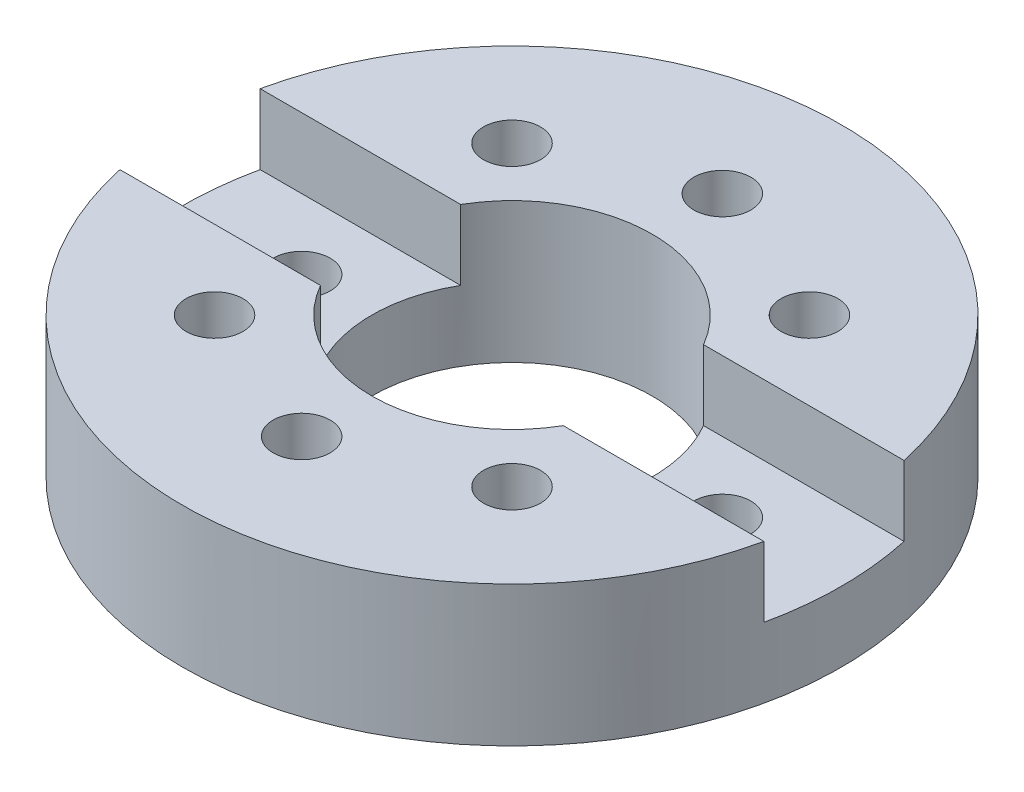
from build123d import *

# Parameters (mm, degrees)
SKETCH1_R           = 2.35
SKETCH1_R_2         = 0.2032
BOSS_EXTRUDE1_DEPTH = 1
SKETCH3_R           = 1
CUT_EXTRUDE1_DEPTH  = 2
CUT_EXTRUDE2_DEPTH  = 0.5


with BuildPart() as part:
    # Sketch1 → Boss-Extrude1 (new body)
    with BuildSketch(Plane(origin=(0, 0, 0), x_dir=(1, 0, 0), z_dir=(0, 1, 0))):
        Circle(SKETCH1_R)
        with Locations((0, 1.5)):
            Circle(SKETCH1_R_2, mode=Mode.SUBTRACT)
        with Locations((1.060660172, 1.060660172)):
            Circle(SKETCH1_R_2, mode=Mode.SUBTRACT)
        with Locations((1.5, 0)):
            Circle(SKETCH1_R_2, mode=Mode.SUBTRACT)
        with Locations((1.060660172, -1.060660172)):
            Circle(SKETCH1_R_2, mode=Mode.SUBTRACT)
        with Locations((0, -1.5)):
            Circle(SKETCH1_R_2, mode=Mode.SUBTRACT)
        with Locations((-1.060660172, -1.060660172)):
            Circle(SKETCH1_R_2, mode=Mode.SUBTRACT)
        with Locations((-1.5, 0)):
            Circle(SKETCH1_R_2, mode=Mode.SUBTRACT)
        with Locations((-1.060660172, 1.060660172)):
            Circle(SKETCH1_R_2, mode=Mode.SUBTRACT)
    extrude(amount=BOSS_EXTRUDE1_DEPTH)

    # Sketch3 → Cut-Extrude1 (cut, through all)
    with BuildSketch(Plane(origin=(0, 1, 0), x_dir=(1, 0, 0), z_dir=(0, 1, 0))):
        Circle(SKETCH3_R)
    extrude(amount=-CUT_EXTRUDE1_DEPTH, mode=Mode.SUBTRACT)

    # Sketch4 → Cut-Extrude2 (cut)
    with BuildSketch(Plane(origin=(0, 1, 0), x_dir=(1, 0, 0), z_dir=(0, 1, 0))):
        with BuildLine():
            Line((-2.35, 0.5), (2.35, 0.5))
            ThreePointArc((2.35, 0.5), (2.85, 0), (2.35, -0.5))
            Line((2.35, -0.5), (-2.35, -0.5))
            ThreePointArc((-2.35, -0.5), (-2.85, 0), (-2.35, 0.5))
        make_face()
    extrude(amount=-CUT_EXTRUDE2_DEPTH, mode=Mode.SUBTRACT)


solid = part.part
